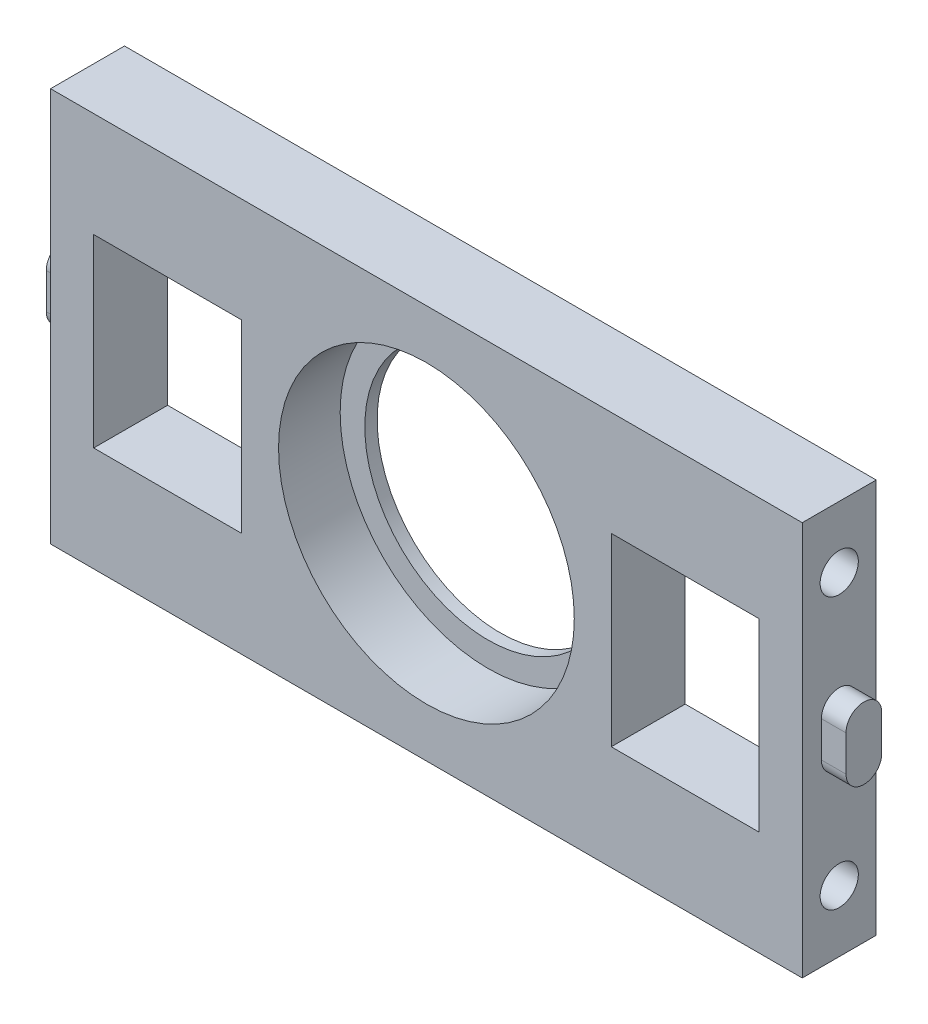
from build123d import *

# Parameters (mm, degrees)
SKETCH_1_W           = 61
SKETCH_1_H           = 32
EXTRUDE_1_DEPTH      = 6
SKETCH_2_R           = 10
CUT_EXTRUDE_13_DEPTH = 6
SKETCH_4_R           = 12
CUT_EXTRUDE_14_DEPTH = 5
SKETCH_5_W           = 12
SKETCH_5_H           = 15
CUT_EXTRUDE_16_DEPTH = 6
EXTRUDE_12_DEPTH     = 2
EXTRUDE_13_DEPTH     = 2
SKETCH_10_R          = 1.55
CUT_EXTRUDE_18_DEPTH = 15
SKETCH_11_R          = 1.55
CUT_EXTRUDE_19_DEPTH = 15


with BuildPart() as part:
    # Эскиз1 → Бобышка-Вытянуть1 (new body)
    with BuildSketch(Plane.XY):
        Rectangle(SKETCH_1_W, SKETCH_1_H)
    extrude(amount=EXTRUDE_1_DEPTH)

    # Эскиз2 → Вырез-Вытянуть13 (cut)
    with BuildSketch(Plane.XY.offset(6)):
        Circle(SKETCH_2_R)
    extrude(amount=-CUT_EXTRUDE_13_DEPTH, mode=Mode.SUBTRACT)

    # Эскиз4 → Вырез-Вытянуть14 (cut)
    with BuildSketch(Plane.XY.offset(6)):
        Circle(SKETCH_4_R)
    extrude(amount=-CUT_EXTRUDE_14_DEPTH, mode=Mode.SUBTRACT)

    # Эскиз5 → Вырез-Вытянуть16 (cut)
    with BuildSketch(Plane.XY.offset(6)):
        with Locations((21, 0)):
            Rectangle(SKETCH_5_W, SKETCH_5_H)
        with Locations((-21, 0)):
            Rectangle(SKETCH_5_W, SKETCH_5_H)
    extrude(amount=-CUT_EXTRUDE_16_DEPTH, mode=Mode.SUBTRACT)

    # Эскиз8 → Бобышка-Вытянуть12 (add)
    with BuildSketch(Plane.ZY.offset(30.5)):
        with BuildLine():
            Line((1.45, -1.5), (1.45, 1.4))
            ThreePointArc((1.45, 1.4), (2.9, 2.85), (4.35, 1.4))
            Line((4.35, 1.4), (4.35, -1.5))
            ThreePointArc((4.35, -1.5), (2.9, -2.95), (1.45, -1.5))
        make_face()
    extrude(amount=EXTRUDE_12_DEPTH)

    # Эскиз9 → Бобышка-Вытянуть13 (add)
    with BuildSketch(Plane(origin=(30.5, 0, 0), x_dir=(0, 0, -1), z_dir=(1, 0, 0))):
        with BuildLine():
            Line((-1.55, 1.45), (-1.55, -1.45))
            ThreePointArc((-1.55, -1.45), (-3, -2.9), (-4.45, -1.45))
            Line((-4.45, -1.45), (-4.45, 1.45))
            ThreePointArc((-4.45, 1.45), (-3, 2.9), (-1.55, 1.45))
        make_face()
    extrude(amount=EXTRUDE_13_DEPTH)

    # Эскиз10 → Вырез-Вытянуть18 (cut)
    with BuildSketch(Plane.ZY.offset(30.5)):
        with Locations(Location((3, 10, 0), (0, 0, 270))):  # turned: the seam where the file's is
            Circle(SKETCH_10_R)
        with Locations(Location((3, -11, 0), (0, 0, 270))):  # turned: the seam where the file's is
            Circle(SKETCH_10_R)
    extrude(amount=-CUT_EXTRUDE_18_DEPTH, mode=Mode.SUBTRACT)

    # Эскиз11 → Вырез-Вытянуть19 (cut)
    with BuildSketch(Plane(origin=(30.5, 0, 0), x_dir=(0, 0, -1), z_dir=(1, 0, 0))):
        with Locations(Location((-3, 11, 0), (0, 0, 90))):  # turned: the seam where the file's is
            Circle(SKETCH_11_R)
        with Locations(Location((-3, -11, 0), (0, 0, 270))):  # turned: the seam where the file's is
            Circle(SKETCH_11_R)
    extrude(amount=-CUT_EXTRUDE_19_DEPTH, mode=Mode.SUBTRACT)


solid = part.part
